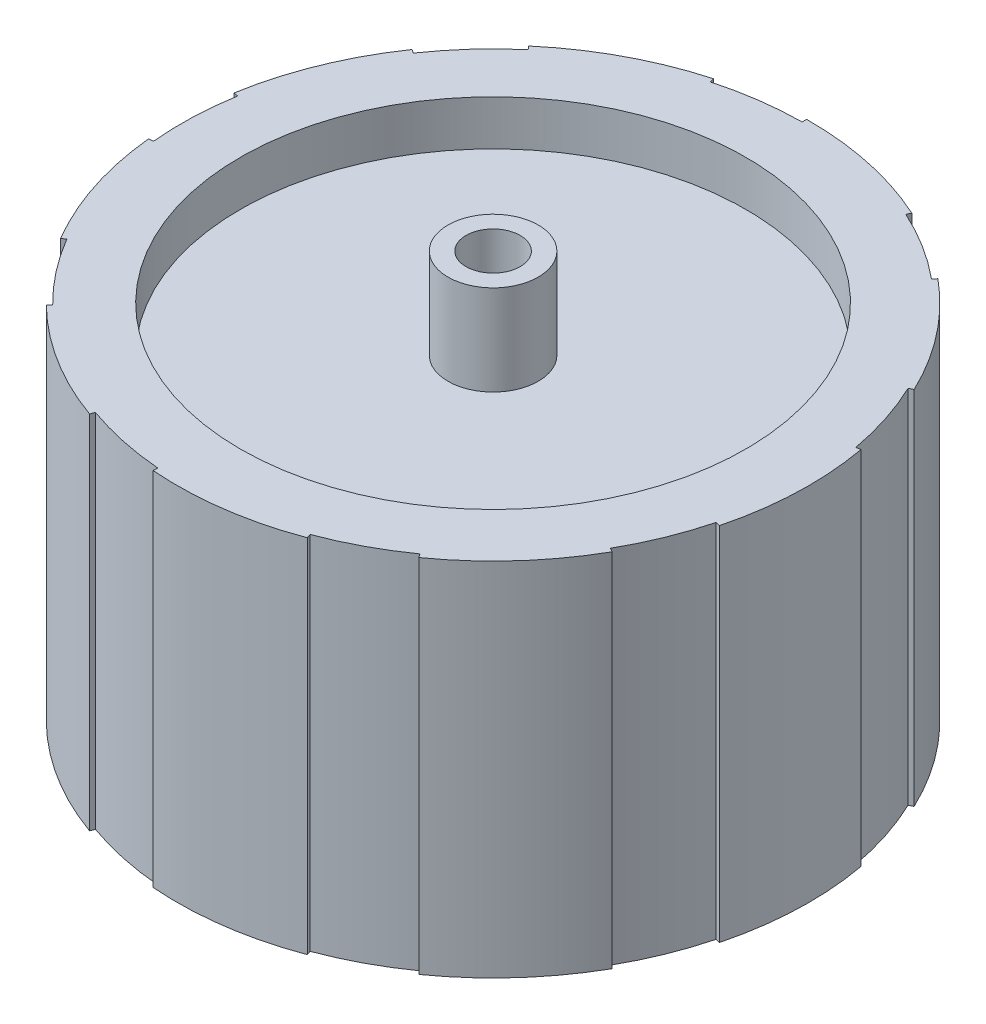
from build123d import *

# Parameters (mm, degrees)
BOSS_EXTRUDE1_DEPTH = 40
SKETCH2_R           = 28
CUT_EXTRUDE1_DEPTH  = 5
SKETCH3_R           = 28
CUT_EXTRUDE2_DEPTH  = 5
SKETCH4_R           = 5
BOSS_EXTRUDE2_DEPTH = 10
SKETCH5_R           = 5
BOSS_EXTRUDE3_DEPTH = 10
SKETCH6_R           = 3
CUT_EXTRUDE3_DEPTH  = 51


with BuildPart() as part:
    # Sketch1 → Boss-Extrude1 (new body)
    with BuildSketch(Plane(origin=(0, 0, 0), x_dir=(1, 0, 0), z_dir=(0, 1, 0))):
        with BuildLine():
            Line((-9.316786783, 33.737182515), (-9.183689829, 33.255222765))
            ThreePointArc((-9.183689829, 33.255222765), (-4.764444491, 34.169431788), (-0.263678186, 34.498992359))
            Line((-0.263678186, 34.498992359), (-0.267499609, 34.998977756))
            ThreePointArc((-0.267499609, 34.998977756), (7.314006433, 34.227259749), (14.548770163, 31.832896298))
            Line((14.548770163, 31.832896298), (14.340930589, 31.378140637))
            ThreePointArc((14.340930589, 31.378140637), (18.313911156, 29.237829231), (21.973535626, 26.597250461))
            Line((21.973535626, 26.597250461), (22.291992664, 26.982717859))
            ThreePointArc((22.291992664, 26.982717859), (27.603712465, 21.518249421), (31.606795859, 15.033644121))
            Line((31.606795859, 15.033644121), (31.155270204, 14.818877776))
            ThreePointArc((31.155270204, 14.818877776), (32.822984237, 10.625521435), (33.92908791, 6.250359477))
            Line((33.92908791, 6.250359477), (34.420813822, 6.340944397))
            ThreePointArc((34.420813822, 6.340944397), (34.977334653, -1.259388959), (33.875650502, -8.800017221))
            Line((33.875650502, -8.800017221), (33.391712637, -8.67430269))
            ThreePointArc((33.391712637, -8.67430269), (31.973818206, -12.95858593), (30.008842881, -17.021144172))
            Line((30.008842881, -17.021144172), (30.443753648, -17.267827421))
            ThreePointArc((30.443753648, -17.267827421), (25.984673227, -23.447745249), (20.293711789, -28.516052704))
            Line((20.293711789, -28.516052704), (20.00380162, -28.108680523))
            ThreePointArc((20.00380162, -28.108680523), (16.163747288, -30.47922692), (12.047126757, -32.328265294))
            Line((12.047126757, -32.328265294), (12.221722797, -32.796790878))
            ThreePointArc((12.221722797, -32.796790878), (4.833494411, -34.664640944), (-2.783880209, -34.889110206))
            Line((-2.783880209, -34.889110206), (-2.744110492, -34.390694346))
            ThreePointArc((-2.744110492, -34.390694346), (-7.209520627, -33.738298895), (-11.551573865, -32.508631796))
            Line((-11.551573865, -32.508631796), (-11.718987979, -32.979771387))
            ThreePointArc((-11.718987979, -32.979771387), (-18.579330159, -29.661565887), (-24.558863718, -24.937165293))
            Line((-24.558863718, -24.937165293), (-24.208022808, -24.580920075))
            ThreePointArc((-24.208022808, -24.580920075), (-27.209373716, -21.210845858), (-29.745164695, -17.477848187))
            Line((-29.745164695, -17.477848187), (-30.176254039, -17.731150335))
            ThreePointArc((-30.176254039, -17.731150335), (-33.298679661, -10.7795145), (-34.842481952, -3.316843594))
            Line((-34.842481952, -3.316843594), (-34.34473221, -3.269460114))
            ThreePointArc((-34.34473221, -3.269460114), (-34.477658444, 1.241397688), (-34.020662383, 5.731014832))
            Line((-34.020662383, 5.731014832), (-34.513715461, 5.814073018))
            ThreePointArc((-34.513715461, 5.814073018), (-32.437206876, 13.146391523), (-28.822915649, 19.855466085))
            Line((-28.822915649, 19.855466085), (-28.411159712, 19.57181657))
            ThreePointArc((-28.411159712, 19.57181657), (-25.61346361, 23.11277746), (-22.377514045, 26.258272319))
            Line((-22.377514045, 26.258272319), (-22.701825842, 26.63882699))
            ThreePointArc((-22.701825842, 26.63882699), (-16.398004495, 30.920954846), (-9.316786783, 33.737182515))
        make_face()
    extrude(amount=BOSS_EXTRUDE1_DEPTH)

    # Sketch2 → Cut-Extrude1 (cut)
    with BuildSketch(Plane(origin=(0, 40, 0), x_dir=(1, 0, 0), z_dir=(0, 1, 0))):
        Circle(SKETCH2_R)
    extrude(amount=-CUT_EXTRUDE1_DEPTH, mode=Mode.SUBTRACT)

    # Sketch3 → Cut-Extrude2 (cut)
    with BuildSketch(Plane.XZ):
        Circle(SKETCH3_R)
    extrude(amount=-CUT_EXTRUDE2_DEPTH, mode=Mode.SUBTRACT)

    # Sketch4 → Boss-Extrude2 (add)
    with BuildSketch(Plane(origin=(0, 35, 0), x_dir=(1, 0, 0), z_dir=(0, 1, 0))):
        Circle(SKETCH4_R)
    extrude(amount=BOSS_EXTRUDE2_DEPTH)

    # Sketch5 → Boss-Extrude3 (add)
    with BuildSketch(Plane.XZ.offset(-5)):
        Circle(SKETCH5_R)
    extrude(amount=BOSS_EXTRUDE3_DEPTH)

    # Sketch6 → Cut-Extrude3 (cut, through all)
    with BuildSketch(Plane.XZ.offset(5)):
        Circle(SKETCH6_R)
    extrude(amount=-CUT_EXTRUDE3_DEPTH, mode=Mode.SUBTRACT)


solid = part.part
